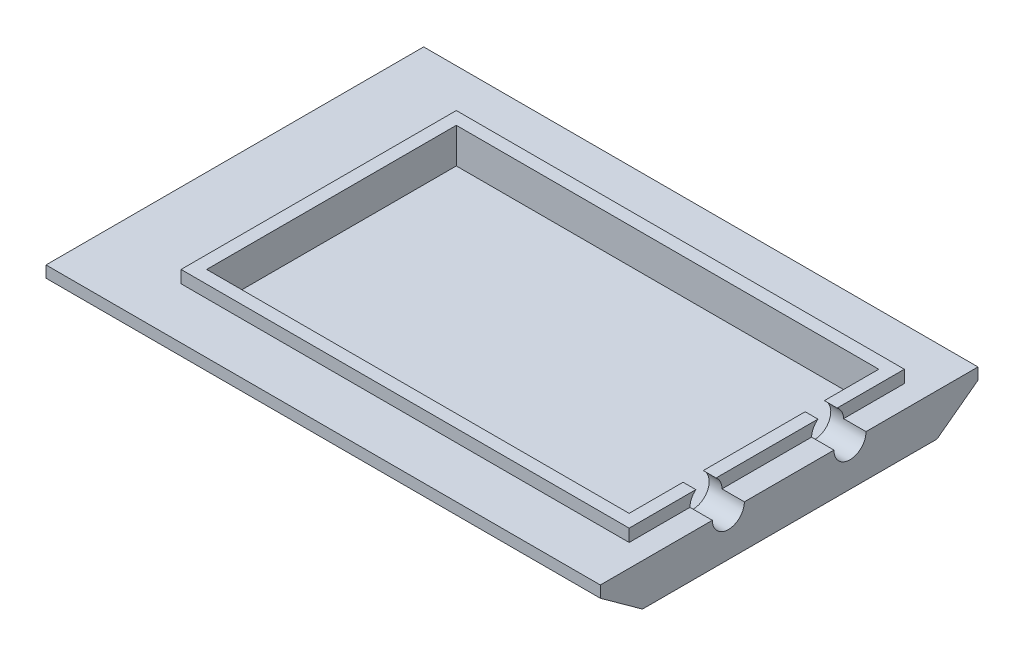
from build123d import *

# Parameters (mm, degrees)
SKETCH2_2_W         = 219.964
SKETCH2_2_H         = 149.86
BOSS_EXTRUDE2_DEPTH = 4.572
SKETCH3_W           = 177.8
SKETCH3_H           = 109.22
BOSS_EXTRUDE3_DEPTH = 5.08
SKETCH4_W           = 167.64
SKETCH4_H           = 99.06
CUT_EXTRUDE1_DEPTH  = 258.8719036
SKETCH4_2_W         = 167.64
SKETCH4_2_H         = 99.06
CUT_EXTRUDE2_DEPTH  = 8.89
SKETCH5_R           = 6.35
CUT_EXTRUDE3_DEPTH  = 19.05


with BuildPart() as part:
    # Sketch2 → Loft1 section 0
    with BuildSketch(Plane(origin=(0, 12.0904, 0), x_dir=(1, 0, 0), z_dir=(0, 1, 0))):
        with BuildLine():
            Line((-219.964, 16.289130435), (0, 16.289130435))
            Line((0, 16.289130435), (0, -133.570869565))
            Line((0, -133.570869565), (-219.964, -133.570869565))
            Line((-219.964, -133.570869565), (-219.964, 16.289130435))
        make_face()
    # Sketch1 → Loft1 section 1
    with BuildSketch(Plane(origin=(0, 0, 0), x_dir=(1, 0, 0), z_dir=(0, 1, 0))):
        with BuildLine():
            Line((-190.5, 0), (0, 0))
            Line((0, 0), (0, -116.84))
            Line((0, -116.84), (-190.5, -116.84))
            Line((-190.5, -116.84), (-190.5, 0))
        make_face()
    loft()

    # Sketch2_2 → Boss-Extrude2 (add)
    with BuildSketch(Plane(origin=(0, 12.0904, 0), x_dir=(1, 0, 0), z_dir=(0, 1, 0))):
        with Locations((-109.982, -58.640869565)):
            Rectangle(SKETCH2_2_W, SKETCH2_2_H)
    extrude(amount=BOSS_EXTRUDE2_DEPTH)

    # Sketch3 → Boss-Extrude3 (add)
    with BuildSketch(Plane(origin=(0, 16.51, 0), x_dir=(1, 0, 0), z_dir=(0, 1, 0))):
        with Locations((-97.79, -58.640869565)):
            Rectangle(SKETCH3_W, SKETCH3_H)
    extrude(amount=BOSS_EXTRUDE3_DEPTH)

    # Sketch4 → Cut-Extrude1 (cut, through all)
    with BuildSketch(Plane(origin=(0, 16.51, 0), x_dir=(1, 0, 0), z_dir=(0, 1, 0))):
        with Locations((-97.79, -58.640869565)):
            Rectangle(SKETCH4_W, SKETCH4_H)
    extrude(amount=CUT_EXTRUDE1_DEPTH, mode=Mode.SUBTRACT)

    # Sketch4_2 → Cut-Extrude2 (cut)
    with BuildSketch(Plane(origin=(0, 16.51, 0), x_dir=(1, 0, 0), z_dir=(0, 1, 0))):
        with Locations((-97.79, -58.640869565)):
            Rectangle(SKETCH4_2_W, SKETCH4_2_H)
    extrude(amount=-CUT_EXTRUDE2_DEPTH, mode=Mode.SUBTRACT)

    # Sketch5 → Cut-Extrude3 (cut)
    with BuildSketch(Plane(origin=(0, 0, 0), x_dir=(0, 0, -1), z_dir=(1, 0, 0))):
        with Locations((-82.770869565, 16.6624)):
            Circle(SKETCH5_R)
        with Locations((-34.510869565, 16.51)):
            Circle(SKETCH5_R)
    extrude(amount=-CUT_EXTRUDE3_DEPTH, mode=Mode.SUBTRACT)


solid = part.part
